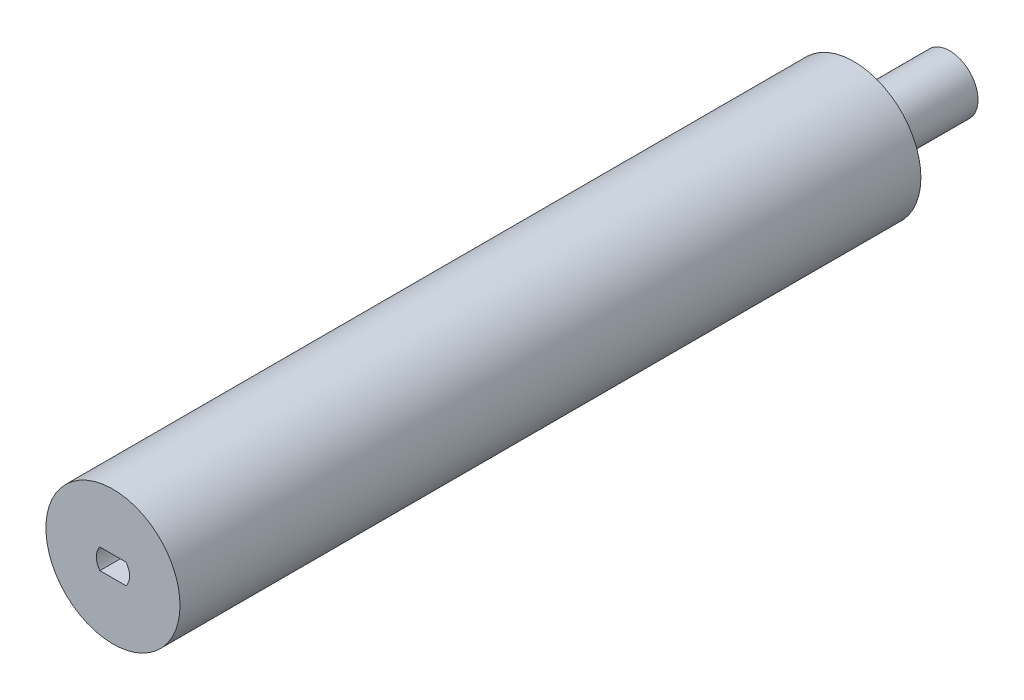
from build123d import *

# Parameters (mm, degrees)
SKETCH2_R           = 10.5
BOSS_EXTRUDE1_DEPTH = 116
SKETCH3_R           = 4.45
BOSS_EXTRUDE2_DEPTH = 15
CUT_EXTRUDE1_DEPTH  = 10


with BuildPart() as part:
    # Sketch2 → Boss-Extrude1 (new body)
    with BuildSketch(Plane.XY):
        Circle(SKETCH2_R)
    extrude(amount=-BOSS_EXTRUDE1_DEPTH)

    # Sketch3 → Boss-Extrude2 (add)
    with BuildSketch(Plane(origin=(0, 0, -116), x_dir=(-1, 0, 0), z_dir=(0, 0, -1))):
        Circle(SKETCH3_R)
    extrude(amount=BOSS_EXTRUDE2_DEPTH)

    # Sketch1 → Cut-Extrude1 (cut)
    with BuildSketch(Plane.XY):
        with BuildLine():
            Line((2.051104302, -1.567413373), (-2.047676004, -1.567413373))
            ThreePointArc((-2.047676004, -1.567413373), (-2.598285851, 0.032586627), (-2.047676004, 1.632586627))
            Line((-2.047676004, 1.632586627), (2.051104302, 1.632586627))
            ThreePointArc((2.051104302, 1.632586627), (2.601714149, 0.032586627), (2.051104302, -1.567413373))
        make_face()
    extrude(amount=-CUT_EXTRUDE1_DEPTH, mode=Mode.SUBTRACT)


solid = part.part
